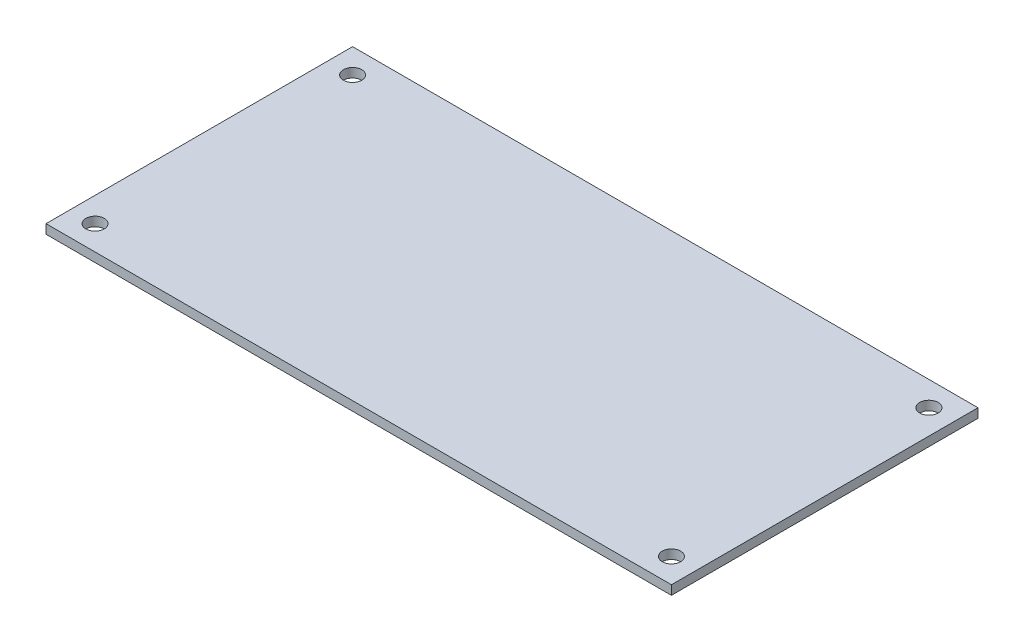
from build123d import *

# Parameters (mm, degrees)
SKETCH1_W           = 102
SKETCH1_H           = 50
SKETCH1_R           = 1.5
BOSS_EXTRUDE1_DEPTH = 1.5


with BuildPart() as part:
    # Sketch1 → Boss-Extrude1 (new body)
    with BuildSketch(Plane(origin=(0, 0, 0), x_dir=(1, 0, 0), z_dir=(0, 1, 0))):
        Rectangle(SKETCH1_W, SKETCH1_H)
        with Locations((-47, 21)):
            Circle(SKETCH1_R, mode=Mode.SUBTRACT)
        with Locations((47, 21)):
            Circle(SKETCH1_R, mode=Mode.SUBTRACT)
        with Locations((47, -21)):
            Circle(SKETCH1_R, mode=Mode.SUBTRACT)
        with Locations((-47, -21)):
            Circle(SKETCH1_R, mode=Mode.SUBTRACT)
    extrude(amount=BOSS_EXTRUDE1_DEPTH)


solid = part.part
